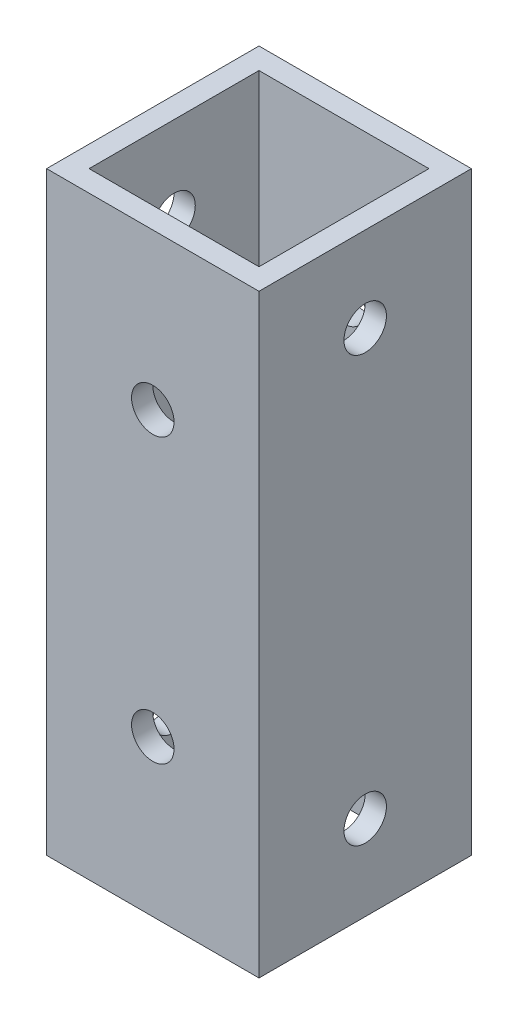
from build123d import *

# Parameters (mm, degrees)
SKETCH1_W           = 15
SKETCH1_H           = 15
SKETCH1_W_2         = 12
SKETCH1_H_2         = 12
EXTRUDE_THIN1_DEPTH = 42
SKETCH2_R           = 1.5
CUT_EXTRUDE1_DEPTH  = 16
SKETCH3_R           = 1.5
CUT_EXTRUDE2_DEPTH  = 16


with BuildPart() as part:
    # Sketch1 → Extrude-Thin1 (new body)
    with BuildSketch(Plane(origin=(0, 0, 0), x_dir=(1, 0, 0), z_dir=(0, 1, 0))):
        with Locations((7.5, 7.5)):
            Rectangle(SKETCH1_W, SKETCH1_H)
        with Locations((7.5, 7.5)):
            Rectangle(SKETCH1_W_2, SKETCH1_H_2, mode=Mode.SUBTRACT)
    extrude(amount=EXTRUDE_THIN1_DEPTH)

    # Sketch2 → Cut-Extrude1 (cut, through all)
    with BuildSketch(Plane.ZY):
        with Locations((-7.5, 36)):
            Circle(SKETCH2_R)
        with Locations((-7.5, 6)):
            Circle(SKETCH2_R)
    extrude(amount=-CUT_EXTRUDE1_DEPTH, mode=Mode.SUBTRACT)

    # Sketch3 → Cut-Extrude2 (cut, through all)
    with BuildSketch(Plane(origin=(0, 0, -15), x_dir=(-1, 0, 0), z_dir=(0, 0, -1))):
        with Locations((-7.5, 31)):
            Circle(SKETCH3_R)
        with Locations((-7.5, 11)):
            Circle(SKETCH3_R)
    extrude(amount=-CUT_EXTRUDE2_DEPTH, mode=Mode.SUBTRACT)


solid = part.part
